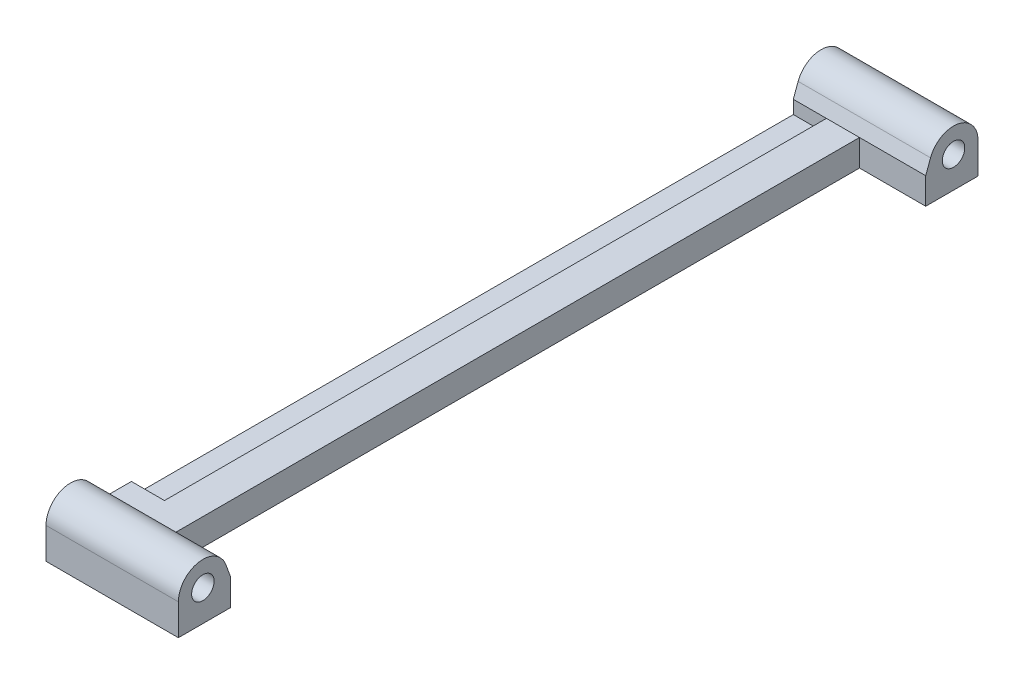
from build123d import *

# Parameters (mm, degrees)
RESSALTO_EXTRUS_O1_DEPTH      = 100
ESBO_O3_W                     = 10
ESBO_O3_H                     = 4
RESSALTO_EXTRUS_O2_DEPTH      = 5
ESBO_O4_R                     = 1.7
RESSALTO_EXTRUS_O3_DEPTH      = 10
RESSALTO_EXTRUS_O3_DEPTH_BACK = 10


with BuildPart() as part:
    # Esbo_o1 → Ressalto-extrus_o1 (new body)
    with BuildSketch(Plane.XY):
        Polygon((0, 0), (0, 2), (5, 2), (5, 4), (10, 4), (10, 0), align=None)
    extrude(amount=RESSALTO_EXTRUS_O1_DEPTH)

    # Esbo_o3 → Ressalto-extrus_o2 (add)
    with BuildSketch(Plane.XY.offset(100)):
        with Locations((5, 2)):
            Rectangle(ESBO_O3_W, ESBO_O3_H)
    extrude(amount=RESSALTO_EXTRUS_O2_DEPTH)

    # Esbo_o4 → Ressalto-extrus_o3 (add, two sides)
    with BuildSketch(Plane(origin=(10, 0, 0), x_dir=(0, 0, -1), z_dir=(1, 0, 0))) as ressalto_extrus_o3_sk:
        with BuildLine():
            Line((-112.9, 4.7), (-112.9, 0))
            Line((-112.9, 0), (-105, 0))
            Line((-105, 0), (-105, 4))
            Line((-105, 4), (-105.72755275, 5.977540643))
            ThreePointArc((-105.72755275, 5.977540643), (-109.848824003, 8.342667623), (-112.9, 4.7))
        make_face()
        with Locations((-109.2, 4.7)):
            Circle(ESBO_O4_R, mode=Mode.SUBTRACT)
        with BuildLine():
            Line((7.9, 0), (0, 0))
            Line((0, 0), (0, 4))
            Line((0, 4), (0.72755275, 5.977540643))
            ThreePointArc((0.72755275, 5.977540643), (4.848824003, 8.342667623), (7.9, 4.7))
            Line((7.9, 4.7), (7.9, 0))
        make_face()
        with Locations((4.2, 4.7)):
            Circle(ESBO_O4_R, mode=Mode.SUBTRACT)
    extrude(amount=RESSALTO_EXTRUS_O3_DEPTH)
    extrude(ressalto_extrus_o3_sk.sketch, amount=-RESSALTO_EXTRUS_O3_DEPTH_BACK)


solid = part.part
